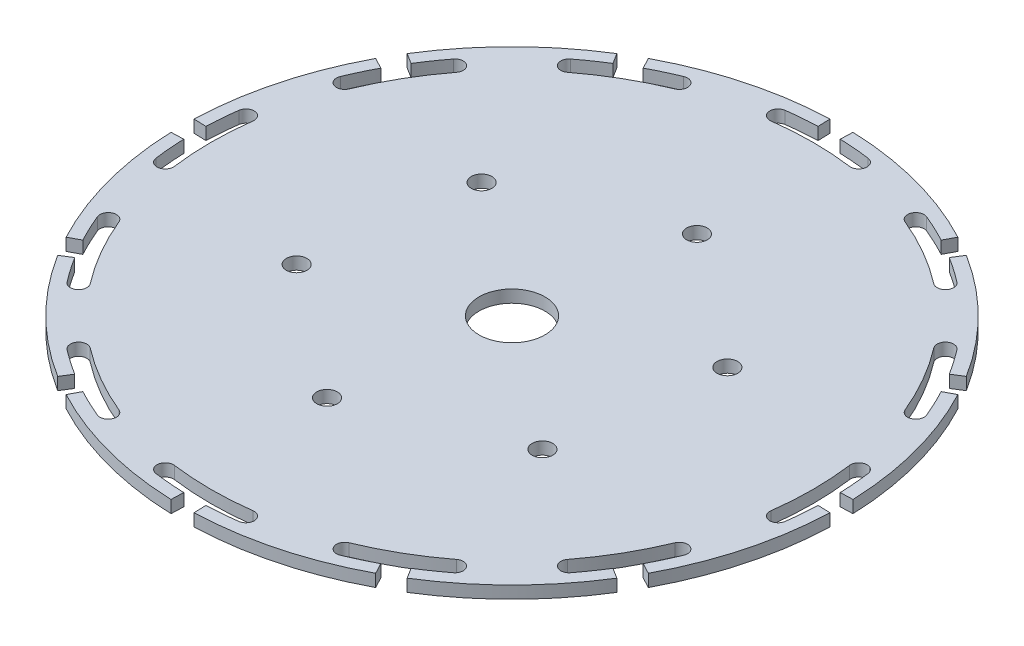
from build123d import *

# Parameters (mm, degrees)
SKETCH1_R         = 40
WHEEL_BLANK_DEPTH = 1.5
T_SLOT_DEPTH      = 2.5
CIRPATTERN_COUNT  = 12
SKETCH3_R         = 4
CENTER_HOLE_DEPTH = 6
CIRPATTERN1_COUNT = 6


with BuildPart() as part:
    # Sketch1 → Wheel Blank (new body)
    with BuildSketch(Plane(origin=(0, 0, 0), x_dir=(1, 0, 0), z_dir=(0, 1, 0))):
        Circle(SKETCH1_R)
    extrude(amount=WHEEL_BLANK_DEPTH)

    # Sketch2 → T-Slot (cut, through all)
    with BuildSketch(Plane(origin=(0, 0, 0), x_dir=(1, 0, 0), z_dir=(0, 1, 0))):
        with BuildLine():
            Line((-1.395979868, 39.975633081), (-1.343630623, 38.47654684))
            ThreePointArc((-1.343630623, 38.47654684), (-3.188115989, 38.367771846), (-5.0252584, 38.170627163))
            ThreePointArc((-5.0252584, 38.170627163), (-5.88617707, 37.048656109), (-4.764206016, 36.18773744))
            ThreePointArc((-4.764206016, 36.18773744), (0, 36.5), (4.764206016, 36.18773744))
            ThreePointArc((4.764206016, 36.18773744), (5.88617707, 37.048656109), (5.0252584, 38.170627163))
            ThreePointArc((5.0252584, 38.170627163), (3.188115989, 38.367771846), (1.343630623, 38.47654684))
            Line((1.343630623, 38.47654684), (1.395979868, 39.975633081))
            ThreePointArc((1.395979868, 39.975633081), (0, 40), (-1.395979868, 39.975633081))
        make_face()
    t_slot = extrude(amount=T_SLOT_DEPTH, mode=Mode.SUBTRACT)

    # CirPattern: T-Slot ×12 about axis
    cirpattern_axis = Axis((0, 0, 0), (0, 1, 0))
    for i in range(1, CIRPATTERN_COUNT):
        add(t_slot.rotate(cirpattern_axis, i * 360 / CIRPATTERN_COUNT), mode=Mode.SUBTRACT)

    # Sketch3 → Center Hole (cut)
    with BuildSketch(Plane(origin=(0, 0, 0), x_dir=(1, 0, 0), z_dir=(0, 1, 0))):
        Circle(SKETCH3_R)
    extrude(amount=CENTER_HOLE_DEPTH, mode=Mode.SUBTRACT)

    # Sketch4 → M3 Clearance Hole1 (revolve, cut)
    with BuildSketch(Plane(origin=(2.610523844, 1.5, -19.828897227), x_dir=(0, 0, 1), z_dir=(1, 0, 0))):
        Polygon((0, 0), (0, 10.751075774), (1.25, 10), (1.25, 0), align=None)
    m3_clearance_hole1 = revolve(axis=Axis((2.610523844, 7.85, -19.828897227), (0, -1, 0)), mode=Mode.SUBTRACT)

    # CirPattern1: M3 Clearance Hole1 ×6 about axis
    cirpattern1_axis = Axis((0, 0, 0), (0, 1, 0))
    for i in range(1, CIRPATTERN1_COUNT):
        add(m3_clearance_hole1.rotate(cirpattern1_axis, i * 360 / CIRPATTERN1_COUNT), mode=Mode.SUBTRACT)


solid = part.part
